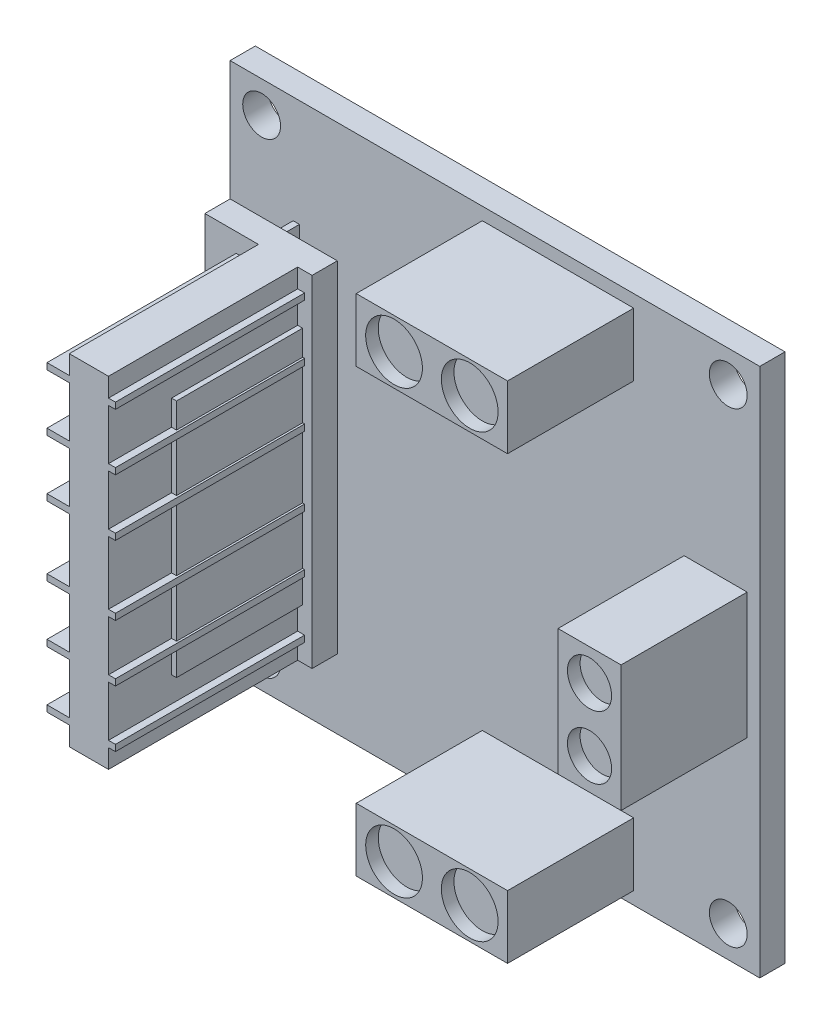
from build123d import *

# Parameters (mm, degrees)
SKETCH1_W           = 42
SKETCH1_H           = 42
BOSS_EXTRUDE1_DEPTH = 2
SKETCH2_W           = 0.5
SKETCH2_H           = 25
BOSS_EXTRUDE2_DEPTH = 2
SKETCH4_W           = 8.5
SKETCH4_H           = 27
BOSS_EXTRUDE3_DEPTH = 2
SKETCH5_W           = 5.42648105
SKETCH5_H           = 0.5
BOSS_EXTRUDE4_DEPTH = 15
SKETCH6_W           = 3.107576182
SKETCH6_H           = 27
BOSS_EXTRUDE5_DEPTH = 15
SKETCH7_W           = 2.5
SKETCH7_H           = 19
BOSS_EXTRUDE6_DEPTH = 10
SKETCH8_W           = 12
SKETCH8_H           = 5
SKETCH8_W_2         = 5
SKETCH8_H_2         = 10
BOSS_EXTRUDE7_DEPTH = 10
SKETCH9_R           = 2.25
SKETCH9_R_2         = 1.75
CUT_EXTRUDE1_DEPTH  = 1
SKETCH10_R          = 1.5
CUT_EXTRUDE2_DEPTH  = 3


with BuildPart() as part:
    # Sketch1 → Boss-Extrude1 (new body)
    with BuildSketch(Plane.XY):
        with Locations((35.471214637, -127.632705913)):
            Rectangle(SKETCH1_W, SKETCH1_H)
    extrude(amount=BOSS_EXTRUDE1_DEPTH)

    # Sketch2 → Boss-Extrude2 (add)
    with BuildSketch(Plane.XY.offset(2)):
        with Locations((19.721214637, -127.632705913)):
            Rectangle(SKETCH2_W, SKETCH2_H)
    extrude(amount=BOSS_EXTRUDE2_DEPTH)

    # Sketch4 → Boss-Extrude3 (add)
    with BuildSketch(Plane.XY.offset(4)):
        with Locations((20.721214637, -127.632705913)):
            Rectangle(SKETCH4_W, SKETCH4_H)
    extrude(amount=BOSS_EXTRUDE3_DEPTH)

    # Sketch5 → Boss-Extrude4 (add)
    with BuildSketch(Plane.XY.offset(6)):
        with Locations((21.665849022, -115.882705913)):
            Rectangle(SKETCH5_W, SKETCH5_H)
        with Locations((21.665849022, -120.382705913)):
            Rectangle(SKETCH5_W, SKETCH5_H)
        with Locations((21.665849022, -124.882705913)):
            Rectangle(SKETCH5_W, SKETCH5_H)
        with Locations((21.665849022, -130.382705913)):
            Rectangle(SKETCH5_W, SKETCH5_H)
        with Locations((21.665849022, -134.882705913)):
            Rectangle(SKETCH5_W, SKETCH5_H)
        with Locations((21.665849022, -139.382705913)):
            Rectangle(SKETCH5_W, SKETCH5_H)
    extrude(amount=BOSS_EXTRUDE4_DEPTH)

    # Sketch6 → Boss-Extrude5 (add)
    with BuildSketch(Plane.XY.offset(6)):
        with Locations((22.275002728, -127.632705913)):
            Rectangle(SKETCH6_W, SKETCH6_H)
    extrude(amount=BOSS_EXTRUDE5_DEPTH)

    # Sketch7 → Boss-Extrude6 (add)
    with BuildSketch(Plane.XY.offset(6)):
        with Locations((22.971214637, -127.632705913)):
            Rectangle(SKETCH7_W, SKETCH7_H)
    extrude(amount=BOSS_EXTRUDE6_DEPTH)

    # Sketch8 → Boss-Extrude7 (add)
    with BuildSketch(Plane.XY.offset(2)):
        with Locations((40.471214637, -110.132705913)):
            Rectangle(SKETCH8_W, SKETCH8_H)
        with Locations((40.471214637, -145.132705913)):
            Rectangle(SKETCH8_W, SKETCH8_H)
        with Locations((52.971214637, -127.632705913)):
            Rectangle(SKETCH8_W_2, SKETCH8_H_2)
    extrude(amount=BOSS_EXTRUDE7_DEPTH)

    # Sketch9 → Cut-Extrude1 (cut)
    with BuildSketch(Plane.XY.offset(12)):
        with Locations((37.471214637, -110.132705913)):
            Circle(SKETCH9_R)
        with Locations((43.471214637, -110.132705913)):
            Circle(SKETCH9_R)
        with Locations((52.971214637, -125.132705913)):
            Circle(SKETCH9_R_2)
        with Locations((52.971214637, -130.132705913)):
            Circle(SKETCH9_R_2)
        with Locations((43.471214637, -145.132705913)):
            Circle(SKETCH9_R)
        with Locations((37.471214637, -145.132705913)):
            Circle(SKETCH9_R)
    extrude(amount=-CUT_EXTRUDE1_DEPTH, mode=Mode.SUBTRACT)

    # Sketch10 → Cut-Extrude2 (cut, through all)
    with BuildSketch(Plane.XY.offset(2)):
        with Locations((53.971214637, -109.132705913)):
            Circle(SKETCH10_R)
        with Locations((16.971214637, -109.132705913)):
            Circle(SKETCH10_R)
        with Locations((16.971214637, -146.132705913)):
            Circle(SKETCH10_R)
        with Locations((53.971214637, -146.132705913)):
            Circle(SKETCH10_R)
    extrude(amount=-CUT_EXTRUDE2_DEPTH, mode=Mode.SUBTRACT)


solid = part.part
